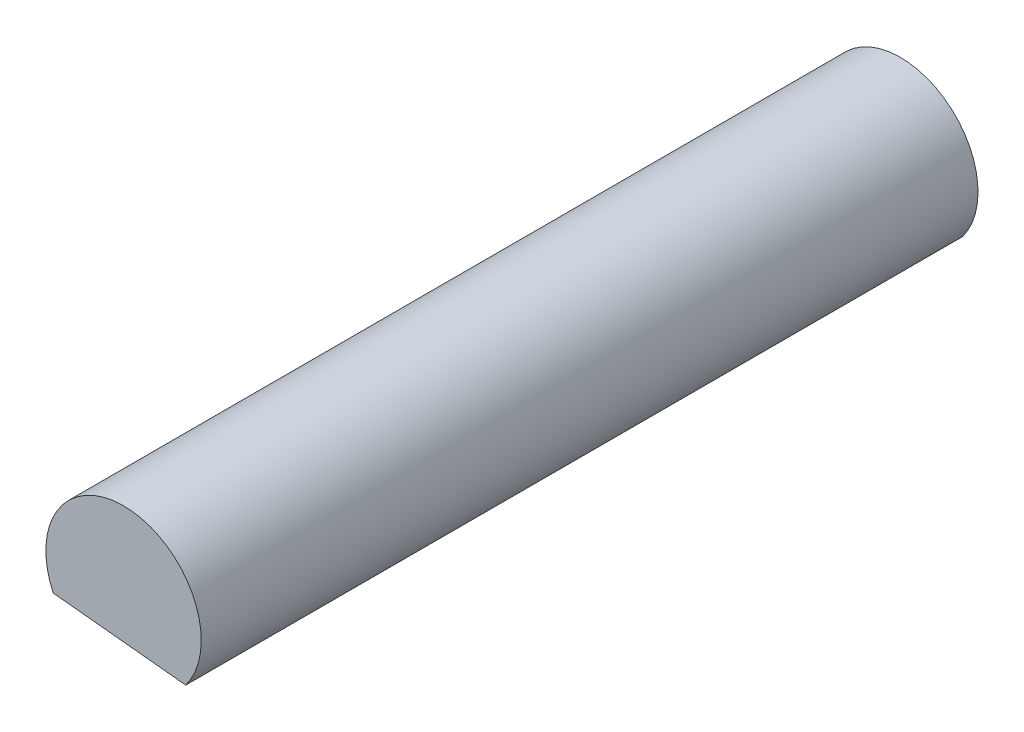
from build123d import *

# Parameters (mm, degrees)
BOSS_EXTRUDE1_DEPTH = 350


with BuildPart() as part:
    # Sketch1 → Boss-Extrude1 (new body)
    with BuildSketch(Plane.XY):
        with BuildLine():
            Line((28.019839707, -20.973520992), (-31.671624033, -14.896584545))
            ThreePointArc((-31.671624033, -14.896584545), (3.544879594, 34.820020515), (28.019839707, -20.973520992))
        make_face()
    extrude(amount=BOSS_EXTRUDE1_DEPTH)


solid = part.part
